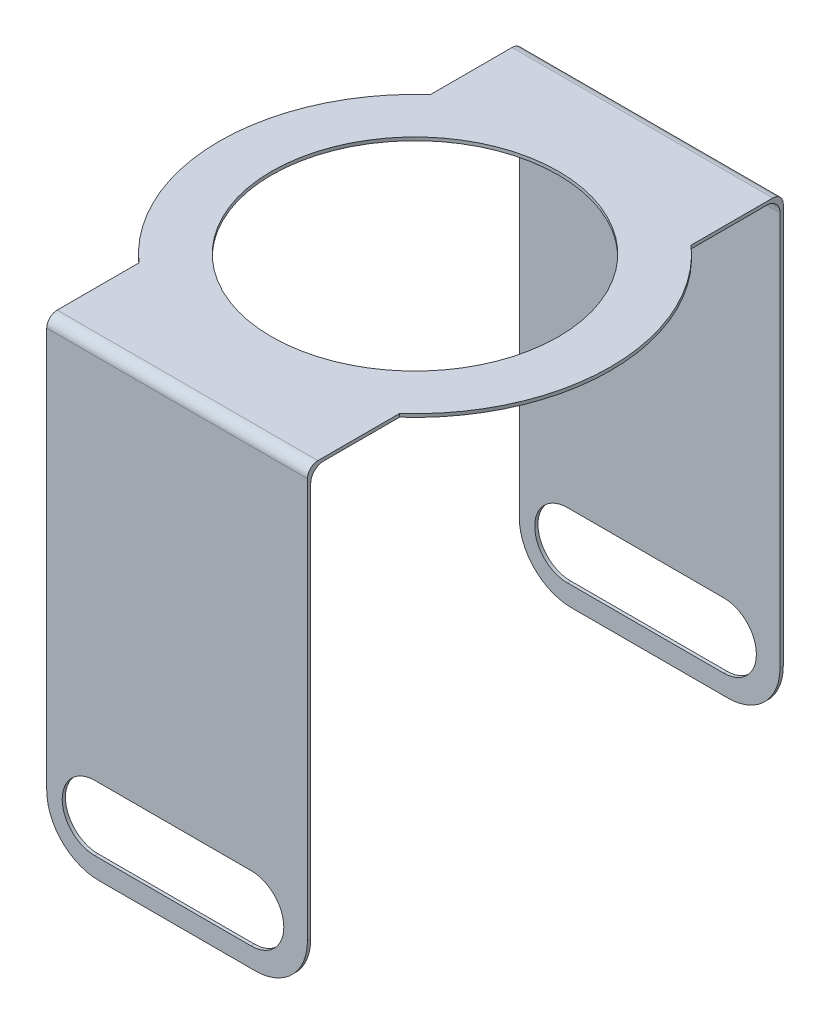
from build123d import *

# Parameters (mm, degrees)
BOSS_EXTRUDE1_DEPTH = 0.125
SKETCH3_W           = 0.125
SKETCH3_H           = 15.25
BOSS_EXTRUDE2_DEPTH = 15.766908
SKETCH4_W           = 15.766907998
SKETCH4_H           = 0.125
BOSS_EXTRUDE3_DEPTH = 2.5
CUT_EXTRUDE1_DEPTH  = 2.5
FILLET1_R           = 0.4
FILLET2_R           = 0.5
FILLET3_R           = 0.5
FILLET4_R           = 2
FILLET5_R           = 2
FILLET6_R           = 0.4
CUT_EXTRUDE2_START  = -17.75
CUT_EXTRUDE2_DEPTH  = 17.75
FILLET7_R           = 2


with BuildPart() as part:
    # Sketch2 → Boss-Extrude1 (new body)
    with BuildSketch(Plane(origin=(0, 0, 0), x_dir=(1, 0, 0), z_dir=(0, 1, 0))):
        with BuildLine():
            Line((-7.883453999, 0), (-5.5, 0))
            ThreePointArc((-5.5, 0), (0, -5.5), (5.5, 0))
            Line((5.5, 0), (7.883453999, 0))
            Line((7.883453999, 0), (7.883453999, -9))
            Line((7.883453999, -9), (-7.883453999, -9))
            Line((-7.883453999, -9), (-7.883453999, 0))
        make_face()
    extrude(amount=BOSS_EXTRUDE1_DEPTH)

    # Sketch3 → Boss-Extrude2 (add)
    with BuildSketch(Plane(origin=(7.883453999, 0, 0), x_dir=(0, 0, -1), z_dir=(1, 0, 0))):
        with Locations((-9.0625, -7.5)):
            Rectangle(SKETCH3_W, SKETCH3_H)
    extrude(amount=-BOSS_EXTRUDE2_DEPTH)

    # Sketch4 → Boss-Extrude3 (add)
    with BuildSketch(Plane.XZ.offset(15.125)):
        with Locations((0, 9.0625)):
            Rectangle(SKETCH4_W, SKETCH4_H)
    extrude(amount=BOSS_EXTRUDE3_DEPTH)

    # Sketch5 → Cut-Extrude1 (cut)
    with BuildSketch(Plane.XY.offset(9.125)):
        with BuildLine():
            Line((-3.156922186, -14.375), (2.843077814, -14.375))
            ThreePointArc((2.843077814, -14.375), (4.093077814, -15.625), (2.843077814, -16.875))
            Line((2.843077814, -16.875), (-3.156922186, -16.875))
            ThreePointArc((-3.156922186, -16.875), (-4.406922186, -15.625), (-3.156922186, -14.375))
        make_face()
    extrude(amount=-CUT_EXTRUDE1_DEPTH, mode=Mode.SUBTRACT)

    # Mirror1: part across plane


with BuildPart() as part_1:
    add(part.part)
    add(part.part.mirror(Plane(origin=(5.5, 0.125, 0), x_dir=(1, 0, 0), z_dir=(0, 0, 1))))

    # Fillet1
    fillet1_edges = [part_1.edges().sort_by_distance(p)[0] for p in [
        (-1e-09, 0.125, 9.125),
    ]]
    fillet(fillet1_edges, radius=FILLET1_R)

    # Fillet2
    fillet2_edges = [part_1.edges().sort_by_distance(p)[0] for p in [
        (0, 0, 9),
    ]]
    fillet(fillet2_edges, radius=FILLET2_R)

    # Fillet3
    fillet3_edges = [part_1.edges().sort_by_distance(p)[0] for p in [
        (0, 0, -9),
    ]]
    fillet(fillet3_edges, radius=FILLET3_R)

    # Fillet4
    fillet4_edges = [part_1.edges().sort_by_distance(p)[0] for p in [
        (7.883453999, -17.625, 9.0625),
        (-7.883453999, -17.625, 9.0625),
    ]]
    fillet(fillet4_edges, radius=FILLET4_R)

    # Fillet5
    fillet5_edges = [part_1.edges().sort_by_distance(p)[0] for p in [
        (7.883453999, -17.625, -9.0625),
        (-7.883453999, -17.625, -9.0625),
    ]]
    fillet(fillet5_edges, radius=FILLET5_R)

    # Fillet6
    fillet6_edges = [part_1.edges().sort_by_distance(p)[0] for p in [
        (-1e-09, 0.125, -9.125),
    ]]
    fillet(fillet6_edges, radius=FILLET6_R)

    # Sketch6 → Cut-Extrude2 (cut)
    with BuildSketch(Plane(origin=(0, 0.125, 0), x_dir=(1, 0, 0), z_dir=(0, 1, 0)).offset(CUT_EXTRUDE2_START)):
        Polygon((7.883453999, -8.725), (5, -8.725), (5, -13.174899539), (11.0971106, -13.174899539), (11.0971106, 15.116605335), (5, 15.116605335), (5, 8.725), (7.883453999, 8.725), align=None)
        Polygon((-5, -13.174899539), (-5, -8.725), (-7.883453999, -8.725), (-7.883453999, 8.725), (-5, 8.725), (-5, 15.116605335), (-11.0971106, 15.116605335), (-11.0971106, -13.174899539), align=None)
        with BuildLine():
            Line((5, -5.590169944), (5, -8.725))
            Line((5, -8.725), (7.883453999, -8.725))
            Line((7.883453999, -8.725), (7.883453999, 8.725))
            Line((7.883453999, 8.725), (5, 8.725))
            Line((5, 8.725), (5, 5.590169944))
            ThreePointArc((5, 5.590169944), (6.846531969, 3.061862178), (7.5, 0))
            ThreePointArc((7.5, 0), (6.846531969, -3.061862178), (5, -5.590169944))
        make_face()
        with BuildLine():
            Line((-7.883453999, -8.725), (-5, -8.725))
            Line((-5, -8.725), (-5, -5.590169944))
            ThreePointArc((-5, -5.590169944), (-7.5, 0), (-5, 5.590169944))
            Line((-5, 5.590169944), (-5, 8.725))
            Line((-5, 8.725), (-7.883453999, 8.725))
            Line((-7.883453999, 8.725), (-7.883453999, -8.725))
        make_face()
    extrude(amount=CUT_EXTRUDE2_DEPTH, mode=Mode.SUBTRACT)

    # Fillet7
    fillet7_edges = [part_1.edges().sort_by_distance(p)[0] for p in [
        (5, -17.625, 9.0625),
        (5, -17.625, -9.0625),
        (-5, -17.625, 9.0625),
        (-5, -17.625, -9.0625),
    ]]
    fillet(fillet7_edges, radius=FILLET7_R)


solid = part_1.part
